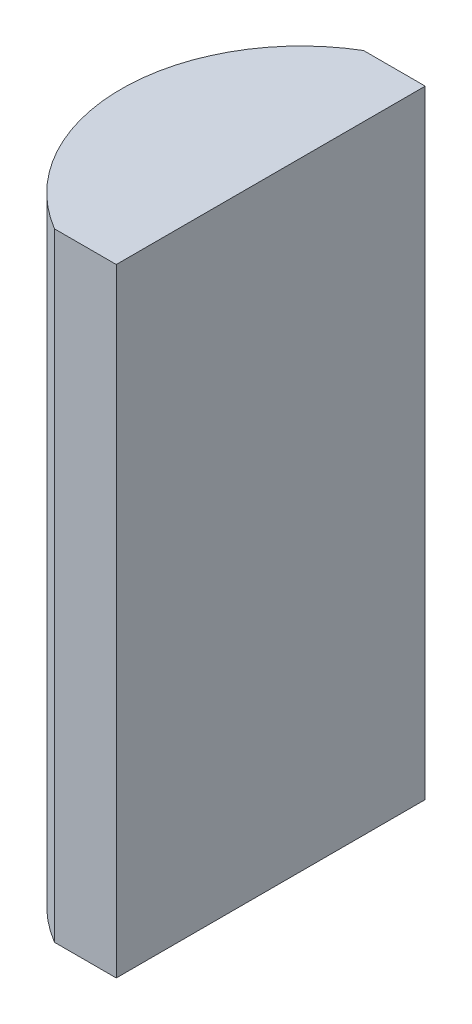
from build123d import *

# Parameters (mm, degrees)
EXTRUDE_1_DEPTH = 20


with BuildPart() as part:
    # 草图1 → 凸台-拉伸1 (new body)
    with BuildSketch(Plane(origin=(0, 0, 0), x_dir=(1, 0, 0), z_dir=(0, 1, 0))):
        with BuildLine():
            Line((1.376546919, 5), (3.375204335, 5))
            Line((3.375204335, 5), (3.375204335, -5))
            Line((3.375204335, -5), (1.376546919, -5))
            ThreePointArc((1.376546919, -5), (-1.464795665, 0), (1.376546919, 5))
        make_face()
    extrude(amount=EXTRUDE_1_DEPTH)


solid = part.part
